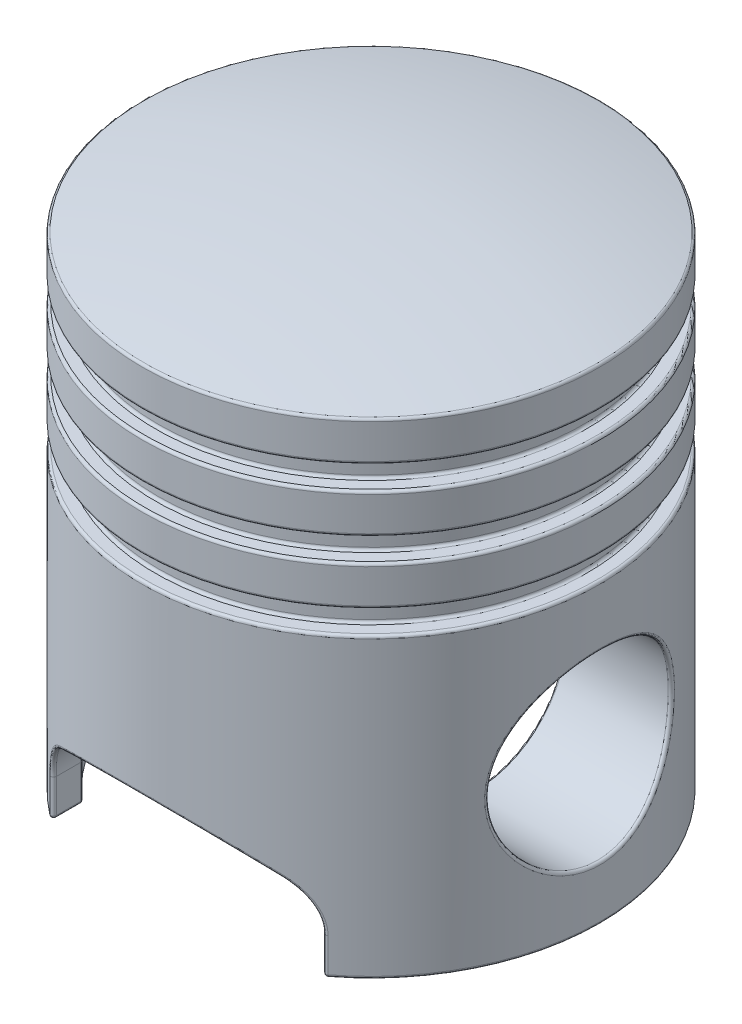
from build123d import *

# Parameters (mm, degrees)
BOSS_EXTRUDE1_REACH      = 133.417
BOSS_EXTRUDE1_END_RADIUS = 38
BOSS_EXTRUDE1_START      = 19
SKETCH2_R                = 22.5
SKETCH3_R                = 16.9
CUT_EXTRUDE1_DEPTH       = 113.41663578
CUT_EXTRUDE1_DEPTH_BACK  = 113.41663578
CUT_EXTRUDE2_START       = -25
CUT_EXTRUDE2_DEPTH       = 30
FILLET1_R                = 10
FILLET1_OF_MIRROR2_R     = 10
FILLET2_R                = 0.5


with BuildPart() as part:
    # Sketch1 → Revolve1 (revolve)
    with BuildSketch(Plane.XY, mode=Mode.PRIVATE) as revolve1_sk:
        with BuildLine():
            Line((0, 95), (0, 85))
            Line((0, 85), (38, 85))
            Line((38, 85), (38, 0))
            Line((38, 0), (42.5, 0))
            Line((42.5, 0), (42.5, 55.2))
            Line((42.5, 55.2), (39.5, 55.2))
            Line((39.5, 55.2), (39.5, 59.5))
            Line((39.5, 59.5), (42.5, 59.5))
            Line((42.5, 59.5), (42.5, 66.8))
            Line((42.5, 66.8), (39.5, 66.8))
            Line((39.5, 66.8), (39.5, 71.1))
            Line((39.5, 71.1), (42.5, 71.1))
            Line((42.5, 71.1), (42.5, 78.4))
            Line((42.5, 78.4), (39.5, 78.4))
            Line((39.5, 78.4), (39.5, 82.7))
            Line((39.5, 82.7), (42.5, 82.7))
            Line((42.5, 82.7), (42.5, 90))
            ThreePointArc((42.5, 90), (21.396553461, 93.745704417), (0, 95))
        make_face()
    revolve(revolve1_sk.sketch.rotate(Axis((0, 0, 0), (0, -1, 0)), 90), axis=Axis((0, 0, 0), (0, -1, 0)))

    # Boss-Extrude1: up to this cylinder (the profile starts inside it)
    boss_extrude1_end = Plane(origin=(0, 27, 0), z_dir=(0, 1, 0)) * Cylinder(BOSS_EXTRUDE1_END_RADIUS, 343.834, mode=Mode.PRIVATE)
    # Sketch2 → Boss-Extrude1 (add, up to the surface)
    with BuildSketch(Plane(origin=(0, 0, 0), x_dir=(0, 0, -1), z_dir=(1, 0, 0)).offset(BOSS_EXTRUDE1_START), mode=Mode.PRIVATE) as boss_extrude1_sk1:
        with Locations(Location((0, 27, 0), (0, 0, 180))):
            Circle(SKETCH2_R)
    boss_extrude1_tool1 = extrude(boss_extrude1_sk1.sketch, amount=BOSS_EXTRUDE1_REACH, mode=Mode.PRIVATE) & boss_extrude1_end
    boss_extrude1 = boss_extrude1_tool1.solids().sort_by_distance((19, 27, 0))[0]
    add(boss_extrude1)

    # Mirror1: Boss-Extrude1 across plane
    add(boss_extrude1.mirror(Plane(origin=(0, 0, 0), x_dir=(0, 0, 1), z_dir=(1, 0, 0))))

    # Sketch3 → Cut-Extrude1 (cut, two sides)
    with BuildSketch(Plane(origin=(0, 0, 0), x_dir=(0, 0, -1), z_dir=(1, 0, 0))) as cut_extrude1_sk:
        with Locations(Location((0, 27, 0), (0, 0, 90))):
            Circle(SKETCH3_R)
    extrude(amount=CUT_EXTRUDE1_DEPTH, mode=Mode.SUBTRACT)
    extrude(cut_extrude1_sk.sketch, amount=-CUT_EXTRUDE1_DEPTH_BACK, mode=Mode.SUBTRACT)

    # Sketch4 → Cut-Extrude2 (cut)
    with BuildSketch(Plane.XY.offset(CUT_EXTRUDE2_START)):
        with BuildLine():
            Line((-25, 0), (-25, 12))
            ThreePointArc((-25, 12), (0, 20.775010008), (25, 12))
            Line((25, 12), (25, 0))
            Line((25, 0), (-25, 0))
        make_face()
    cut_extrude2 = extrude(amount=-CUT_EXTRUDE2_DEPTH, mode=Mode.SUBTRACT)

    # Fillet1
    fillet1_edges = [part.edges().sort_by_distance(p)[0] for p in [
        (25, 12, -31.493746877),
        (-25, 12, -31.493746877),
    ]]
    fillet(fillet1_edges, radius=FILLET1_R)

    # Mirror2: Cut-Extrude2 across plane
    add(cut_extrude2.mirror(Plane.XY), mode=Mode.SUBTRACT)

    # Fillet1 of Mirror2
    fillet1_of_mirror2_edges = [part.edges().sort_by_distance(p)[0] for p in [
        (25, 12, 31.493746877),
        (-25, 12, 31.493746877),
    ]]
    fillet(fillet1_of_mirror2_edges, radius=FILLET1_OF_MIRROR2_R)

    # Fillet2
    fillet2_edges = [part.edges().sort_by_distance(p)[0] for p in [
        (42.5, 0, 0),
        (38, 0, 0),
        (-25, 0, 31.493746877),
        (25, 0, 31.493746877),
        (-25, 3.377886061, 28.618176043),
        (25, 3.377886061, 34.369317712),
        (25, 3.377886061, 28.618176043),
        (10.689336437, 19.320283209, 36.465573987),
        (10.613095316, 19.341345168, 41.153519991),
        (-25, 3.377886061, 34.369317712),
        (23.553713653, 11.935924897, 29.819835231),
        (23.579234265, 11.893547789, 35.359153137),
        (-23.553713653, 11.935924897, 29.819835231),
        (-23.579234311, 11.893547826, 35.359153114),
        (0, 85, -38),
        (0, 55.2, -42.5),
        (0, 55.2, -39.5),
        (0, 59.5, -39.5),
        (0, 59.5, -42.5),
        (0, 66.8, -42.5),
        (0, 66.8, -39.5),
        (0, 71.1, -39.5),
        (0, 71.1, -42.5),
        (0, 78.4, -42.5),
        (0, 78.4, -39.5),
        (0, 82.7, -39.5),
        (0, 82.7, -42.5),
        (0, 90, -42.5),
        (30.622703996, 27, -22.5),
        (19, 27, -22.5),
        (-30.622703996, 27, -22.5),
        (-19, 27, -22.5),
        (-19, 10.1, 0),
        (-42.5, 10.1, 0),
        (19, 10.1, 0),
        (42.5, 10.1, 0),
        (-42.5, 0, 0),
        (-38, 0, 0),
        (25, 0, -31.493746877),
        (-25, 0, -31.493746877),
        (-25, 3.377886061, -28.618176043),
        (25, 3.377886061, -34.369317712),
        (0, 20.775010008, -42.5),
        (0, 20.775010007, -37.999999999),
        (25, 3.377886061, -28.618176043),
        (-25, 3.377886061, -34.369317712),
        (23.553713653, 11.935924897, -29.819835231),
        (23.579234311, 11.893547826, -35.359153114),
        (-23.553713653, 11.935924897, -29.819835231),
        (-23.57923429, 11.893547806, -35.359153133),
    ]]
    fillet(fillet2_edges, radius=FILLET2_R)


solid = part.part
